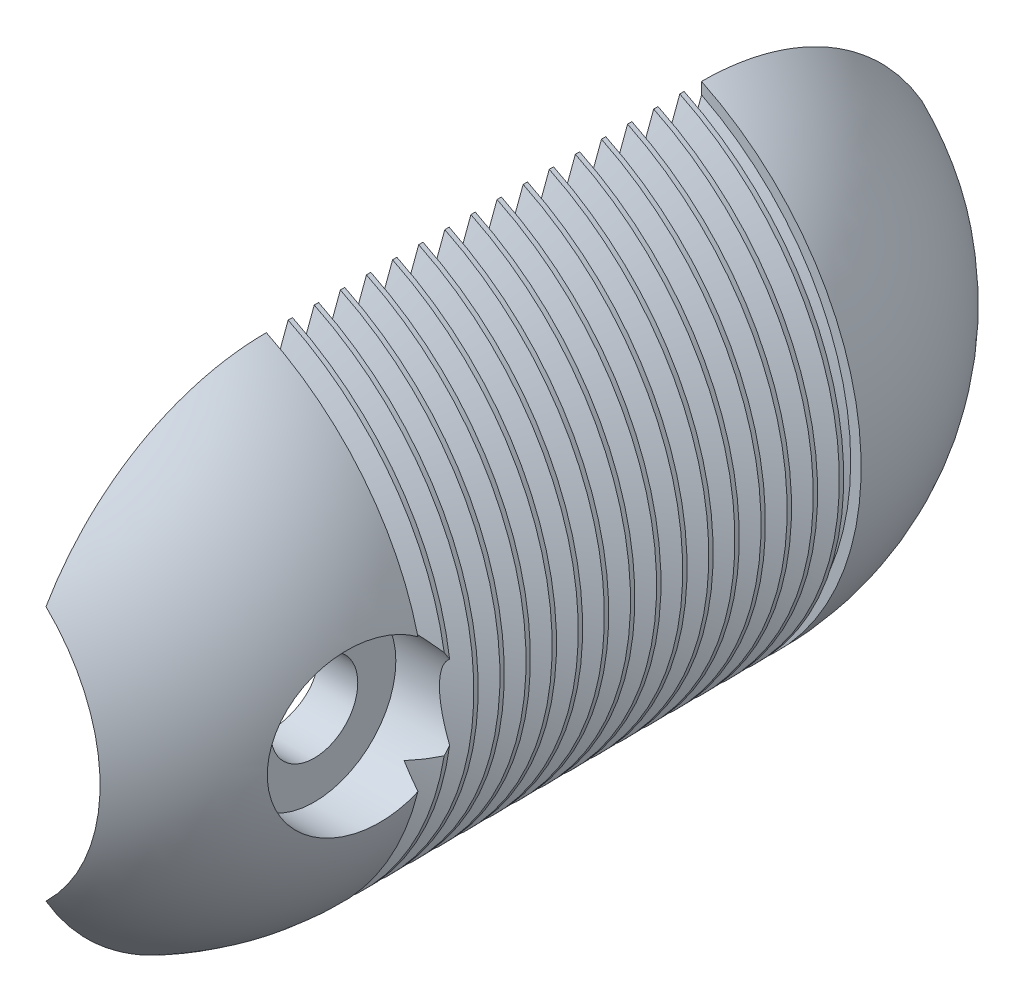
from build123d import *

# Parameters (mm, degrees)
BODY_ANGLE                  = 180
HOLE_FOR_HANDLE_DEPTH       = 7.5
SKETCH6_R                   = 1.1303
F_5_40_SET_SCREW_HOLE_DEPTH = 7
SKETCH8_R                   = 0.75
HOLE_FOR_CABLE_DEPTH        = 7
SKETCH9_R                   = 6.5
SKETCH9_R_2                 = 0.75
BOSS_EXTRUDE1_DEPTH         = 10
LPATTERN1_COUNT             = 17
LPATTERN1_PITCH             = 0.6
SKETCH10_R                  = 0.8
F_2X0_4_SCREW_HOLE_DEPTH    = 14
SKETCH11_R                  = 1
CUT_EXTRUDE5_DEPTH          = 4
SKETCH12_R                  = 1.875
CUT_EXTRUDE6_DEPTH          = 1.5
REVOLVE4_ANGLE              = 180
SKETCH14_R                  = 0.75
CUT_EXTRUDE7_DEPTH          = 7.5
SKETCH15_W                  = 14.877439366
SKETCH15_H                  = 30.132348637
CUT_EXTRUDE9_DEPTH          = 14.0000001


with BuildPart() as part:
    # Sketch3 → body (revolve)
    with BuildSketch(Plane.XY):
        with BuildLine():
            Line((0, 6.5), (0, -6.5))
            ThreePointArc((0, -6.5), (6.5, 0), (0, 6.5))
        make_face()
    revolve(axis=Axis((0, 6.5, 0), (0, -1, 0)), revolution_arc=BODY_ANGLE)

    # Sketch5 → hole for handle (cut, through all)
    with BuildSketch(Plane(origin=(0, 0, 0), x_dir=(-1, 0, 0), z_dir=(0, 0, -1))):
        with BuildLine():
            Line((1.5, 3.688881761), (1.5, 2.702827207))
            Line((1.5, 2.702827207), (-1.5, 2.702827207))
            Line((-1.5, 2.702827207), (-1.5, 3.688881761))
            Line((-1.5, 3.688881761), (-1.5, 3.788881761))
            ThreePointArc((-1.5, 3.788881761), (0, -4.075), (1.5, 3.788881761))
            Line((1.5, 3.788881761), (1.5, 3.688881761))
        make_face()
    extrude(amount=-HOLE_FOR_HANDLE_DEPTH, mode=Mode.SUBTRACT)

    # Sketch6 → 5-40 set screw hole (cut)
    with BuildSketch(Plane(origin=(0, 6.5, 0), x_dir=(1, 0, 0), z_dir=(0, 1, 0))):
        with Locations((0, -1.564027547)):
            Circle(SKETCH6_R)
    extrude(amount=-F_5_40_SET_SCREW_HOLE_DEPTH, mode=Mode.SUBTRACT)

    # Sketch8 → hole for cable (cut)
    with BuildSketch(Plane(origin=(0, 0, 0), x_dir=(-1, 0, 0), z_dir=(0, 0, -1))):
        with Locations((0, 4.237225844)):
            Circle(SKETCH8_R)
    extrude(amount=-HOLE_FOR_CABLE_DEPTH, mode=Mode.SUBTRACT)

    # Sketch9 → Boss-Extrude1 (add)
    with BuildSketch(Plane(origin=(0, 0, 0), x_dir=(-1, 0, 0), z_dir=(0, 0, -1))):
        Circle(SKETCH9_R)
        with Locations((0, 4.237225844)):
            Circle(SKETCH9_R_2, mode=Mode.SUBTRACT)
        with BuildLine():
            Line((-1.5, 2.702827207), (-1.5, 3.788881761))
            ThreePointArc((-1.5, 3.788881761), (0, -4.075), (1.5, 3.788881761))
            Line((1.5, 3.788881761), (1.5, 2.702827207))
            Line((1.5, 2.702827207), (-1.5, 2.702827207))
        make_face(mode=Mode.SUBTRACT)
    extrude(amount=BOSS_EXTRUDE1_DEPTH)

    # Sketch17 → Cut-Revolve1 (revolve, cut)
    with BuildSketch(Plane(origin=(0, 0, 0), x_dir=(1, 0, 0), z_dir=(0, 1, 0))):
        Polygon((6.5, 0), (5.9, 0.25), (6.5, 0.5), align=None)
    cut_revolve1 = revolve(axis=Axis((0, 0, -10.795570318), (0, 0, 1)), mode=Mode.SUBTRACT)

    # LPattern1: Cut-Revolve1 ×17
    with Locations(*[(0, 0, -i * LPATTERN1_PITCH) for i in range(1, LPATTERN1_COUNT)]):
        add(cut_revolve1, mode=Mode.SUBTRACT)

    # Sketch10 → 2X0.4 screw hole (cut, through all)
    with BuildSketch(Plane(origin=(6.5, 0, 0), x_dir=(0, 0, -1), z_dir=(1, 0, 0))):
        with Locations((-1.067713855, 0)):
            Circle(SKETCH10_R)
    extrude(amount=-F_2X0_4_SCREW_HOLE_DEPTH, mode=Mode.SUBTRACT)

    # Sketch11 → Cut-Extrude5 (cut)
    with BuildSketch(Plane(origin=(6.5, 0, 0), x_dir=(0, 0, -1), z_dir=(1, 0, 0))):
        with Locations((-1.067713855, 0)):
            Circle(SKETCH11_R)
    extrude(amount=-CUT_EXTRUDE5_DEPTH, mode=Mode.SUBTRACT)

    # Sketch12 → Cut-Extrude6 (cut)
    with BuildSketch(Plane(origin=(6.5, 0, 0), x_dir=(0, 0, -1), z_dir=(1, 0, 0))):
        with Locations((-1.067713855, 0)):
            Circle(SKETCH12_R)
    extrude(amount=-CUT_EXTRUDE6_DEPTH, mode=Mode.SUBTRACT)

    # Sketch13 → Revolve4 (revolve)
    with BuildSketch(Plane(origin=(0, 0, -10), x_dir=(-1, 0, 0), z_dir=(0, 0, -1))):
        with BuildLine():
            Line((0, 6.5), (0, -6.5))
            ThreePointArc((0, -6.5), (6.5, 0), (0, 6.5))
        make_face()
    revolve(axis=Axis((0, 6.5, -10), (0, -1, 0)), revolution_arc=REVOLVE4_ANGLE)

    # Sketch14 → Cut-Extrude7 (cut, through all)
    with BuildSketch(Plane.XY.offset(-10)):
        with Locations((0, 4.237225844)):
            Circle(SKETCH14_R)
        with BuildLine():
            Line((1.5, 3.788881761), (1.5, 2.702827207))
            Line((1.5, 2.702827207), (-1.5, 2.702827207))
            Line((-1.5, 2.702827207), (-1.5, 3.788881761))
            ThreePointArc((-1.5, 3.788881761), (0, -4.075), (1.5, 3.788881761))
        make_face()
    extrude(amount=-CUT_EXTRUDE7_DEPTH, mode=Mode.SUBTRACT)

    # Sketch15 → Cut-Extrude9 (cut, through all)
    with BuildSketch(Plane(origin=(0, 6.5, 0), x_dir=(1, 0, 0), z_dir=(0, 1, 0))):
        with Locations((-4.606536683, 5.735579818)):
            Rectangle(SKETCH15_W, SKETCH15_H)
    extrude(amount=-CUT_EXTRUDE9_DEPTH, mode=Mode.SUBTRACT)


solid = part.part
